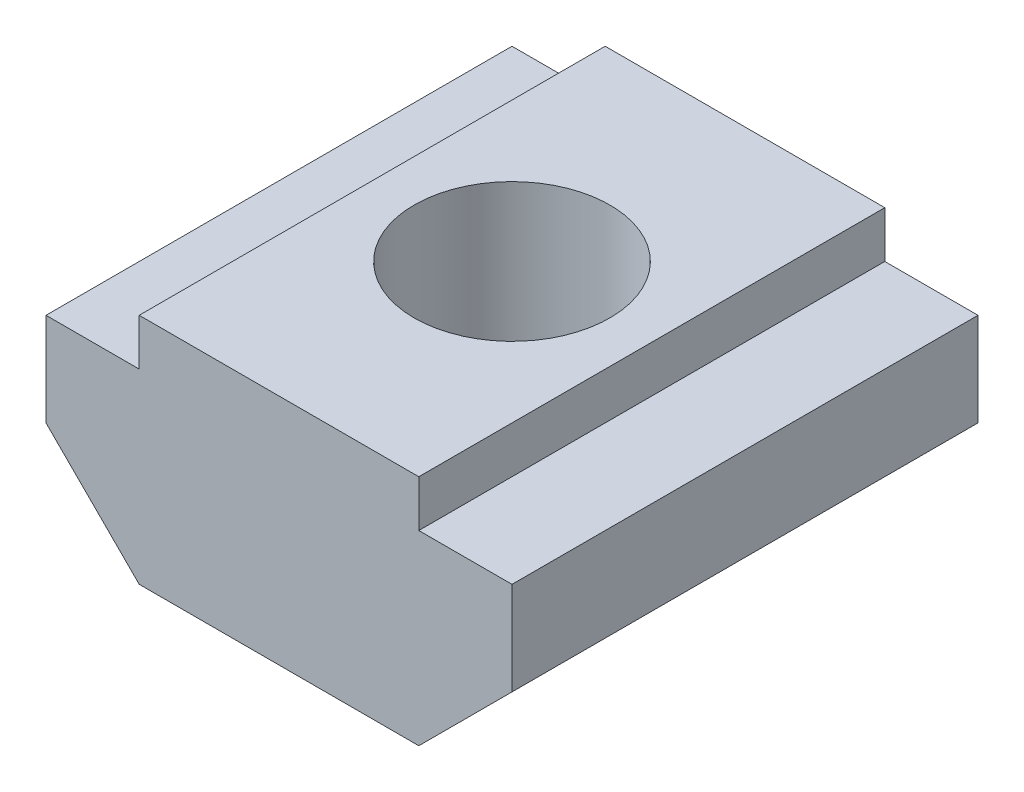
from build123d import *

# Parameters (mm, degrees)
BOSS_EXTRUDE1_DEPTH = 5
SKETCH2_R           = 2.1
CUT_EXTRUDE1_DEPTH  = 6


with BuildPart() as part:
    # Sketch1 → Boss-Extrude1 (new body, symmetric)
    with BuildSketch(Plane.XY):
        Polygon((-5, 1.5), (-5, -0.5), (-3, -2.5), (3, -2.5), (5, -0.5), (5, 1.5), (3, 1.5), (3, 2.5), (-3, 2.5), (-3, 1.5), align=None)
    extrude(amount=BOSS_EXTRUDE1_DEPTH, both=True)

    # Sketch2 → Cut-Extrude1 (cut, through all)
    with BuildSketch(Plane(origin=(0, 2.5, 0), x_dir=(1, 0, 0), z_dir=(0, 1, 0))):
        Circle(SKETCH2_R)
    extrude(amount=-CUT_EXTRUDE1_DEPTH, mode=Mode.SUBTRACT)


solid = part.part
